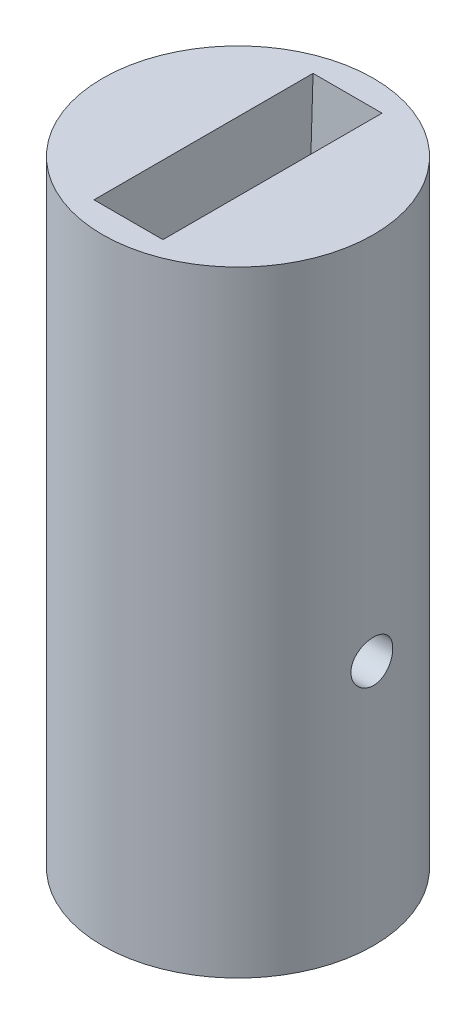
from build123d import *

# Parameters (mm, degrees)
SKETCH2_W          = 11
SKETCH2_H          = 50
CUT_EXTRUDE1_DEPTH = 2.8


with BuildPart() as part:
    # Sketch2 → Revolve1 (revolve)
    with BuildSketch(Plane(origin=(0, 0, 0), x_dir=(0, 0, -1), z_dir=(1, 0, 0))):
        with Locations((5.5, -360)):
            Rectangle(SKETCH2_W, SKETCH2_H)
    revolve(axis=Axis((0, -385, 0), (0, 1, 0)))

    # Sketch1 → Cut-Extrude1 (cut, symmetric)
    with BuildSketch(Plane(origin=(0, 0, 0), x_dir=(0, 0, -1), z_dir=(1, 0, 0))):
        Polygon((-38.186717683, 609.980512405), (-17.5, -57.391201416), (-7.5, -380), (7.5, -380), (17.5, -57.391201416), (38.186717683, 609.980512405), (38.186717683, 1945.365018378), (-38.186717683, 1945.365018378), align=None)
    extrude(amount=CUT_EXTRUDE1_DEPTH, both=True, mode=Mode.SUBTRACT)

    # Sketch4 → M3 Clearance Hole1 (revolve, cut)
    with BuildSketch(Plane.ZX.offset(-365)):
        Polygon((0, 0), (0, 11), (1.7, 11), (1.7, 0.020977491), (1.725, 0), align=None)
    m3_clearance_hole1 = revolve(axis=Axis((-6.35, -365, 0), (1, 0, 0)), mode=Mode.SUBTRACT)

    # Mirror1: M3 Clearance Hole1 across plane
    add(m3_clearance_hole1.mirror(Plane(origin=(0, 0, 0), x_dir=(0, 0, 1), z_dir=(1, 0, 0))), mode=Mode.SUBTRACT)


solid = part.part
